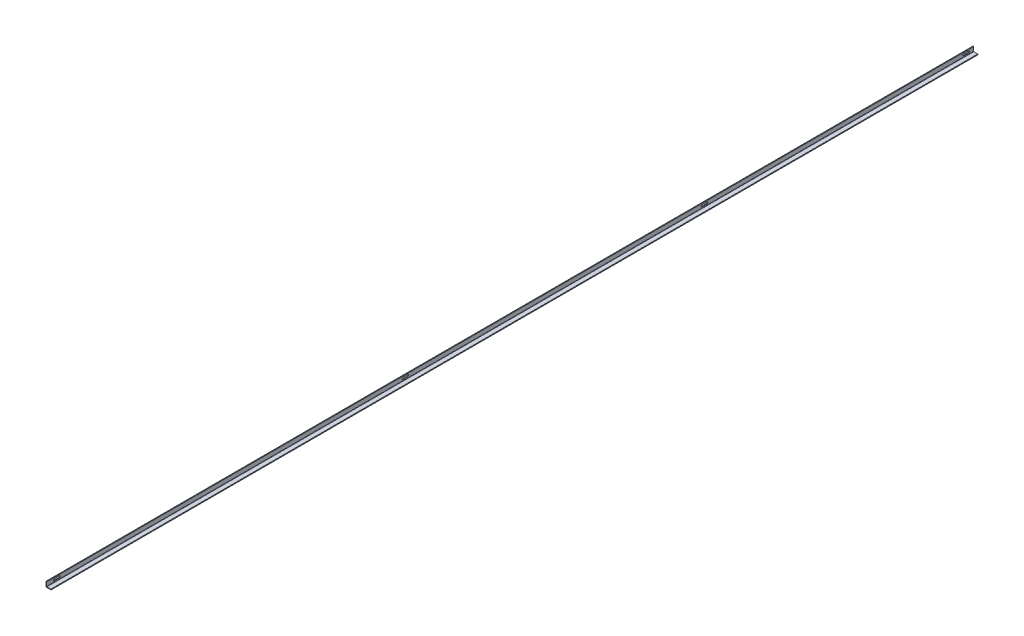
from build123d import *

# Parameters (mm, degrees)
EXTRUDE_THIN1_DEPTH = 4660.9
FILLET1_R           = 1.5875
SLOT_DEPTH          = 4.175
SLOT_2_COUNT        = 2
SLOT_2_PITCH        = 1314.45
SLOT_3_COUNT        = 2
SLOT_3_PITCH        = 2819.4
SLOT_4_COUNT        = 2
SLOT_4_PITCH        = 4572


with BuildPart() as part:
    # Sketch1 → Extrude-Thin1 (new body)
    with BuildSketch(Plane.XY):
        Polygon((0, 25.4), (0, 0), (25.4, 0), (25.4, 3.175), (3.175, 3.175), (3.175, 25.4), align=None)
    extrude(amount=EXTRUDE_THIN1_DEPTH)

    # Fillet1
    fillet1_edges = [part.edges().sort_by_distance(p)[0] for p in [
        (3.175, 3.175, 2330.45),
        (25.4, 3.175, 2330.45),
        (3.175, 25.4, 2330.45),
    ]]
    fillet(fillet1_edges, radius=FILLET1_R)

    # SlotSketch → Slot (cut, through all)
    with BuildSketch(Plane(origin=(3.175, 23.635931813, 4673.560828074), x_dir=(0, 1, 0), z_dir=(1, 0, 0))):
        with BuildLine():
            Line((-4.992331813, -4622.760828074), (-4.992331813, -4648.160828074))
            ThreePointArc((-4.992331813, -4648.160828074), (-9.348431813, -4652.516928074), (-13.704531813, -4648.160828074))
            Line((-13.704531813, -4648.160828074), (-13.704531813, -4622.760828074))
            ThreePointArc((-13.704531813, -4622.760828074), (-9.348431813, -4618.404728074), (-4.992331813, -4622.760828074))
        make_face()
    slot = extrude(amount=-SLOT_DEPTH, mode=Mode.SUBTRACT)

    # Slot 2: Slot ×2
    with Locations(*[(0, 0, i * SLOT_2_PITCH) for i in range(1, SLOT_2_COUNT)]):
        add(slot, mode=Mode.SUBTRACT)

    # Slot 3: Slot ×2
    with Locations(*[(0, 0, i * SLOT_3_PITCH) for i in range(1, SLOT_3_COUNT)]):
        add(slot, mode=Mode.SUBTRACT)

    # Slot 4: Slot ×2
    with Locations(*[(0, 0, i * SLOT_4_PITCH) for i in range(1, SLOT_4_COUNT)]):
        add(slot, mode=Mode.SUBTRACT)


solid = part.part
